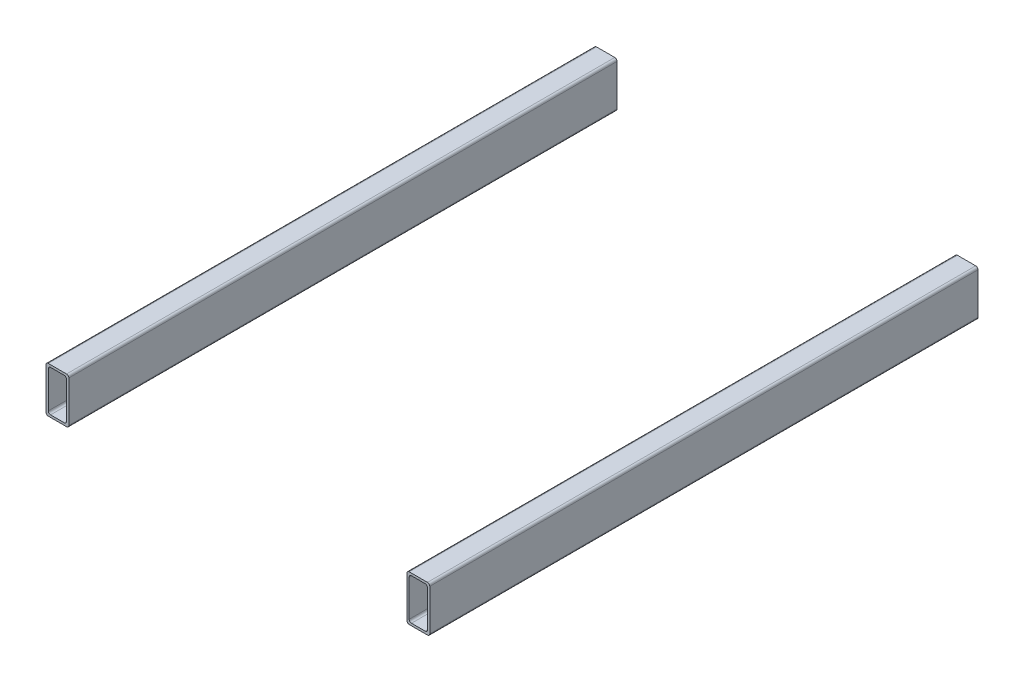
from build123d import *

# Parameters (mm, degrees)
EXTRUDE_1_DEPTH   = 600
EXTRUDE_1_2_DEPTH = 600


with BuildPart() as part:
    # Эскиз1 → Бобышка-Вытянуть1 (new body)
    with BuildSketch(Plane.XY):
        with BuildLine():
            Line((-10, 50), (10, 50))
            ThreePointArc((10, 50), (11.767766953, 49.267766953), (12.5, 47.5))
            Line((12.5, 47.5), (12.5, 2.5))
            ThreePointArc((12.5, 2.5), (11.767766953, 0.732233047), (10, 0))
            Line((10, 0), (-10, 0))
            ThreePointArc((-10, 0), (-11.767766953, 0.732233047), (-12.5, 2.5))
            Line((-12.5, 2.5), (-12.5, 47.5))
            ThreePointArc((-12.5, 47.5), (-11.767766953, 49.267766953), (-10, 50))
        make_face()
        with BuildLine():
            Line((-7.5, 47.5), (7.5, 47.5))
            ThreePointArc((7.5, 47.5), (9.267766953, 46.767766953), (10, 45))
            Line((10, 45), (10, 5))
            ThreePointArc((10, 5), (9.267766953, 3.232233047), (7.5, 2.5))
            Line((7.5, 2.5), (-7.5, 2.5))
            ThreePointArc((-7.5, 2.5), (-9.267766953, 3.232233047), (-10, 5))
            Line((-10, 5), (-10, 45))
            ThreePointArc((-10, 45), (-9.267766953, 46.767766953), (-7.5, 47.5))
        make_face(mode=Mode.SUBTRACT)
    extrude(amount=-EXTRUDE_1_DEPTH)


with BuildPart() as body_2:
    # Эскиз1 → Extrude 1 2 (new body)
    with BuildSketch(Plane.XY):
        with BuildLine():
            Line((385, 50), (405, 50))
            ThreePointArc((405, 50), (406.767766953, 49.267766953), (407.5, 47.5))
            Line((407.5, 47.5), (407.5, 2.5))
            ThreePointArc((407.5, 2.5), (406.767766953, 0.732233047), (405, 0))
            Line((405, 0), (385, 0))
            ThreePointArc((385, 0), (383.232233047, 0.732233047), (382.5, 2.5))
            Line((382.5, 2.5), (382.5, 47.5))
            ThreePointArc((382.5, 47.5), (383.232233047, 49.267766953), (385, 50))
        make_face()
        with BuildLine():
            Line((387.5, 47.5), (402.5, 47.5))
            ThreePointArc((402.5, 47.5), (404.267766953, 46.767766953), (405, 45))
            Line((405, 45), (405, 5))
            ThreePointArc((405, 5), (404.267766953, 3.232233047), (402.5, 2.5))
            Line((402.5, 2.5), (387.5, 2.5))
            ThreePointArc((387.5, 2.5), (385.732233047, 3.232233047), (385, 5))
            Line((385, 5), (385, 45))
            ThreePointArc((385, 45), (385.732233047, 46.767766953), (387.5, 47.5))
        make_face(mode=Mode.SUBTRACT)
    extrude(amount=-EXTRUDE_1_2_DEPTH)


solid = Compound([part.part, body_2.part])
